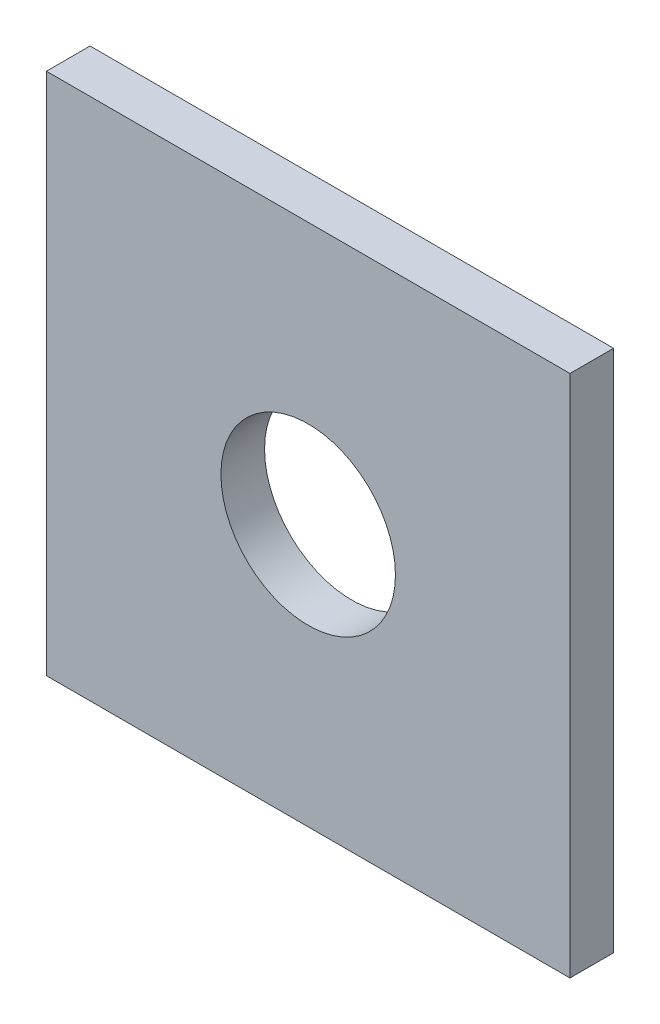
from build123d import *

# Parameters (mm, degrees)
SKETCH1_W           = 76.2
SKETCH1_H           = 76.2
SKETCH1_R           = 12.7
BOSS_EXTRUDE1_DEPTH = 6.35


with BuildPart() as part:
    # Sketch1 → Boss-Extrude1 (new body)
    with BuildSketch(Plane.XY):
        with Locations((38.1, 38.1)):
            Rectangle(SKETCH1_W, SKETCH1_H)
        with Locations((38.1, 38.1)):
            Circle(SKETCH1_R, mode=Mode.SUBTRACT)
    extrude(amount=BOSS_EXTRUDE1_DEPTH)


solid = part.part
